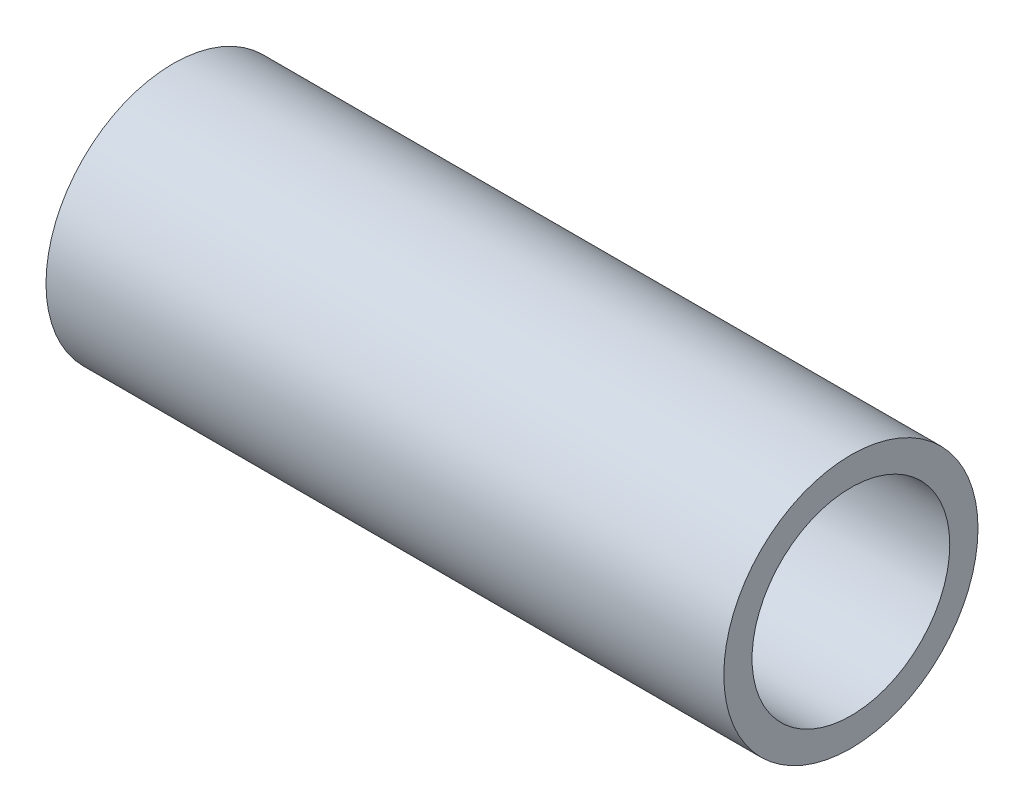
from build123d import *

# Parameters (mm, degrees)
SKETCH1_R           = 9
SKETCH1_R_2         = 7
BOSS_EXTRUDE1_DEPTH = 24


with BuildPart() as part:
    # Sketch1 → Boss-Extrude1 (new body, symmetric)
    with BuildSketch(Plane(origin=(0, 0, 0), x_dir=(0, 0, -1), z_dir=(1, 0, 0))):
        Circle(SKETCH1_R)
        Circle(SKETCH1_R_2, mode=Mode.SUBTRACT)
    extrude(amount=BOSS_EXTRUDE1_DEPTH, both=True)


solid = part.part
